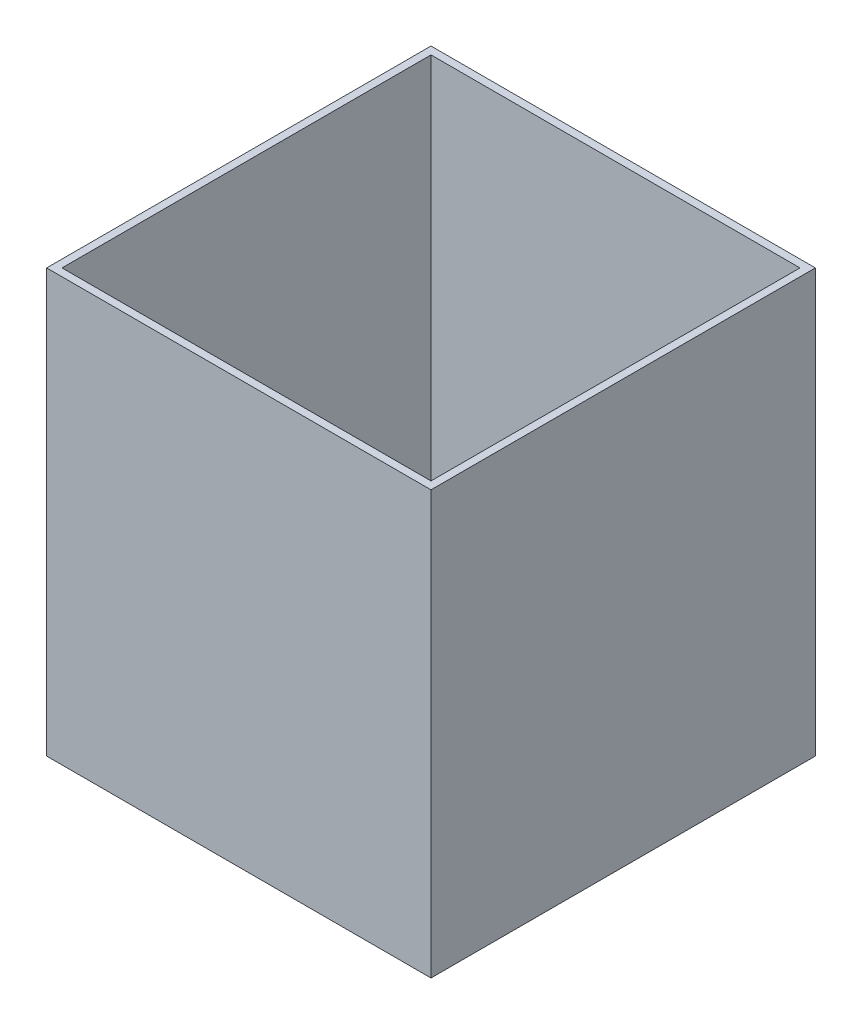
from build123d import *

# Parameters (mm, degrees)
SZKIC1_W                          = 20
SZKIC1_H                          = 20
DODANIE_WYCI_GNI_CIE1_DEPTH       = 2
SZKIC2_W                          = 20
SZKIC2_H                          = 20
SZKIC2_W_2                        = 19.2
SZKIC2_H_2                        = 19.2
WYCI_GNI_CIE_CIENKA_CIANKA1_DEPTH = 20


with BuildPart() as part:
    # Szkic1 → Dodanie-wyciągnięcie1 (new body)
    with BuildSketch(Plane(origin=(0, 0, 0), x_dir=(1, 0, 0), z_dir=(0, 1, 0))):
        Rectangle(SZKIC1_W, SZKIC1_H)
    extrude(amount=DODANIE_WYCI_GNI_CIE1_DEPTH)

    # Szkic2 → Wyciągnięcie-cienka ścianka1 (add)
    with BuildSketch(Plane(origin=(0, 2, 0), x_dir=(1, 0, 0), z_dir=(0, 1, 0))):
        Rectangle(SZKIC2_W, SZKIC2_H)
        Rectangle(SZKIC2_W_2, SZKIC2_H_2, mode=Mode.SUBTRACT)
    extrude(amount=WYCI_GNI_CIE_CIENKA_CIANKA1_DEPTH)


solid = part.part
